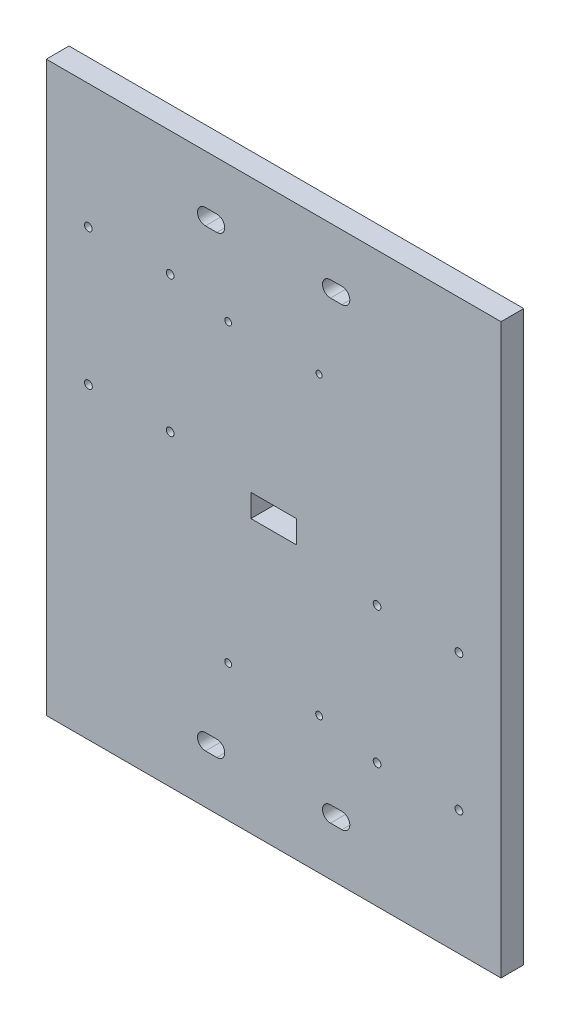
from build123d import *

# Parameters (mm, degrees)
ESQUISSE2_W             = 200
ESQUISSE2_H             = 250
BOSS_EXTRU_1_DEPTH      = 10
ESQUISSE7_W             = 20
ESQUISSE7_H             = 10
ENL_V_MAT_EXTRU_2_DEPTH = 10
ENL_V_MAT_EXTRU_3_DEPTH = 10
ESQUISSE11_R            = 1.5
ESQUISSE11_R_2          = 1.37656202
ENL_V_MAT_EXTRU_4_DEPTH = 10
D_GAGEMENT_M31_D        = 3.4


with BuildPart() as part:
    # Esquisse2 → Boss.-Extru.1 (new body)
    with BuildSketch(Plane.XY):
        with Locations((100, -125)):
            Rectangle(ESQUISSE2_W, ESQUISSE2_H)
    extrude(amount=BOSS_EXTRU_1_DEPTH)

    # Esquisse7 → Enlèv. mat.-Extru.2 (cut)
    with BuildSketch(Plane(origin=(0, 0, 0), x_dir=(-1, 0, 0), z_dir=(0, 0, -1))):
        with Locations((-100, -125)):
            Rectangle(ESQUISSE7_W, ESQUISSE7_H)
    extrude(amount=-ENL_V_MAT_EXTRU_2_DEPTH, mode=Mode.SUBTRACT)

    # Esquisse10 → Enlèv. mat.-Extru.3 (cut)
    with BuildSketch(Plane(origin=(0, 0, 0), x_dir=(-1, 0, 0), z_dir=(0, 0, -1))):
        with BuildLine():
            Line((-70, -28.5), (-75, -28.5))
            ThreePointArc((-75, -28.5), (-78.5, -25), (-75, -21.5))
            Line((-75, -21.5), (-70, -21.5))
            ThreePointArc((-70, -21.5), (-66.5, -25), (-70, -28.5))
        make_face()
        with BuildLine():
            Line((-70, -228.5), (-75, -228.5))
            ThreePointArc((-75, -228.5), (-78.5, -225), (-75, -221.5))
            Line((-75, -221.5), (-70, -221.5))
            ThreePointArc((-70, -221.5), (-66.5, -225), (-70, -228.5))
        make_face()
        with BuildLine():
            Line((-130, -221.5), (-125, -221.5))
            ThreePointArc((-125, -221.5), (-121.5, -225), (-125, -228.5))
            Line((-125, -228.5), (-130, -228.5))
            ThreePointArc((-130, -228.5), (-133.5, -225), (-130, -221.5))
        make_face()
        with BuildLine():
            Line((-130, -21.5), (-125, -21.5))
            ThreePointArc((-125, -21.5), (-121.5, -25), (-125, -28.5))
            Line((-125, -28.5), (-130, -28.5))
            ThreePointArc((-130, -28.5), (-133.5, -25), (-130, -21.5))
        make_face()
    extrude(amount=-ENL_V_MAT_EXTRU_3_DEPTH, mode=Mode.SUBTRACT)

    # Esquisse11 → Enlèv. mat.-Extru.4 (cut)
    with BuildSketch(Plane(origin=(0, 0, 0), x_dir=(-1, 0, 0), z_dir=(0, 0, -1))):
        with Locations((-80, -190)):
            Circle(ESQUISSE11_R)
        with Locations((-120, -190)):
            Circle(ESQUISSE11_R)
        with Locations((-80, -60)):
            Circle(ESQUISSE11_R)
        with Locations((-120, -60)):
            Circle(ESQUISSE11_R_2)
    extrude(amount=-ENL_V_MAT_EXTRU_4_DEPTH, mode=Mode.SUBTRACT)

    # Dégagement M31 (through all)
    with Locations(Plane.XY.offset(10)):
        with Locations((18.5, -54.7), (54.5, -54.7), (18.545923706, -114.7), (54.5, -114.7), (145.5, -135.3), (181.5, -135.3), (145.5, -195.3), (181.5, -195.3)):
            Hole(D_GAGEMENT_M31_D / 2)


solid = part.part
